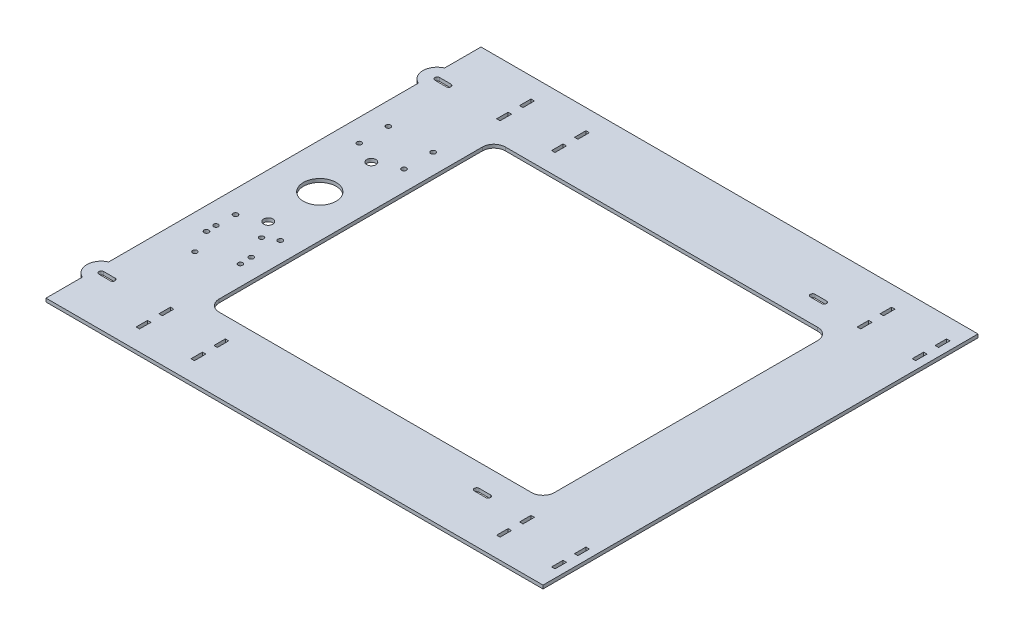
from build123d import *

# Parameters (mm, degrees)
SKETCH1_W           = 434.18
SKETCH1_H           = 380
BOSS_EXTRUDE1_DEPTH = 3
SKETCH2_W           = 250
SKETCH2_H           = 250
CUT_EXTRUDE1_DEPTH  = 4
SKETCH3_W           = 3
SKETCH3_H           = 10
CUT_EXTRUDE2_DEPTH  = 4
SKETCH6_R           = 14.2875
SKETCH6_R_2         = 2
SKETCH6_R_3         = 2.083333333
SKETCH6_R_4         = 4
CUT_EXTRUDE3_DEPTH  = 4
SKETCH7_W           = 83.283399819
SKETCH7_H           = 250
CUT_EXTRUDE4_DEPTH  = 4
FILLET1_R           = 10
CUT_EXTRUDE5_DEPTH  = 4
SKETCH9_R           = 12.5
BOSS_EXTRUDE2_DEPTH = 3


with BuildPart() as part:
    # Sketch1 → Boss-Extrude1 (new body)
    with BuildSketch(Plane(origin=(0, 0, 0), x_dir=(1, 0, 0), z_dir=(0, 1, 0))):
        Rectangle(SKETCH1_W, SKETCH1_H)
    extrude(amount=BOSS_EXTRUDE1_DEPTH)

    # Sketch2 → Cut-Extrude1 (cut, through all)
    with BuildSketch(Plane(origin=(0, 3, 0), x_dir=(1, 0, 0), z_dir=(0, 1, 0))):
        with Locations((27.09, 0)):
            Rectangle(SKETCH2_W, SKETCH2_H)
    extrude(amount=-CUT_EXTRUDE1_DEPTH, mode=Mode.SUBTRACT)

    # Sketch3 → Cut-Extrude2 (cut, through all)
    with BuildSketch(Plane(origin=(0, 3, 0), x_dir=(1, 0, 0), z_dir=(0, 1, 0))):
        with Locations((160.59, -147.5)):
            Rectangle(SKETCH3_W, SKETCH3_H)
        with Locations((160.59, -167.5)):
            Rectangle(SKETCH3_W, SKETCH3_H)
        with Locations((208.59, -147.5)):
            Rectangle(SKETCH3_W, SKETCH3_H)
        with Locations((208.59, -167.5)):
            Rectangle(SKETCH3_W, SKETCH3_H)
        with Locations((-154.41, -147.5)):
            Rectangle(SKETCH3_W, SKETCH3_H)
        with Locations((-154.41, -167.5)):
            Rectangle(SKETCH3_W, SKETCH3_H)
        with Locations((-106.41, -167.5)):
            Rectangle(SKETCH3_W, SKETCH3_H)
        with Locations((-106.41, -147.5)):
            Rectangle(SKETCH3_W, SKETCH3_H)
        with Locations((208.59, 147.5)):
            Rectangle(SKETCH3_W, SKETCH3_H)
        with Locations((208.59, 167.5)):
            Rectangle(SKETCH3_W, SKETCH3_H)
        with Locations((160.59, 167.5)):
            Rectangle(SKETCH3_W, SKETCH3_H)
        with Locations((160.59, 147.5)):
            Rectangle(SKETCH3_W, SKETCH3_H)
        with Locations((-106.41, 147.5)):
            Rectangle(SKETCH3_W, SKETCH3_H)
        with Locations((-106.41, 167.5)):
            Rectangle(SKETCH3_W, SKETCH3_H)
        with Locations((-154.41, 167.5)):
            Rectangle(SKETCH3_W, SKETCH3_H)
        with Locations((-154.41, 147.5)):
            Rectangle(SKETCH3_W, SKETCH3_H)
    extrude(amount=-CUT_EXTRUDE2_DEPTH, mode=Mode.SUBTRACT)

    # Sketch6 → Cut-Extrude3 (cut, through all)
    with BuildSketch(Plane(origin=(0, 3, 0), x_dir=(1, 0, 0), z_dir=(0, 1, 0))):
        with Locations((-177.91, 10)):
            Circle(SKETCH6_R)
        with Locations((-197.793356941, -60.788209542)):
            Circle(SKETCH6_R_2)
        with Locations((-187.137790458, -89.899356941)):
            Circle(SKETCH6_R_2)
        with Locations((-158.026643059, -79.243790458)):
            Circle(SKETCH6_R_2)
        with Locations((-168.682209542, -50.132643059)):
            Circle(SKETCH6_R_2)
        with Locations((-158.345, 64.0505)):
            Circle(SKETCH6_R_3)
        with Locations((-197.475, 64.0505)):
            Circle(SKETCH6_R_3)
        with Locations((-197.475, -44.0505)):
            Circle(SKETCH6_R_3)
        with Locations((-158.345, -44.0505)):
            Circle(SKETCH6_R_3)
        with Locations((-197.475, 89.4505)):
            Circle(SKETCH6_R_3)
        with Locations((-158.345, 89.4505)):
            Circle(SKETCH6_R_3)
        with Locations((-158.345, -69.4505)):
            Circle(SKETCH6_R_3)
        with Locations((-197.475, -69.4505)):
            Circle(SKETCH6_R_3)
        with Locations((-177.91, -35)):
            Circle(SKETCH6_R_4)
        with Locations((-177.91, 55)):
            Circle(SKETCH6_R_4)
    extrude(amount=-CUT_EXTRUDE3_DEPTH, mode=Mode.SUBTRACT)

    # Sketch7 → Cut-Extrude4 (cut, through all)
    with BuildSketch(Plane(origin=(0, 3, 0), x_dir=(1, 0, 0), z_dir=(0, 1, 0))):
        with Locations((-99.169040346, 0)):
            Rectangle(SKETCH7_W, SKETCH7_H)
    extrude(amount=-CUT_EXTRUDE4_DEPTH, mode=Mode.SUBTRACT)

    # Fillet1
    fillet1_edges = [part.edges().sort_by_distance(p)[0] for p in [
        (152.09, 1.5, -125),
        (152.09, 1.5, 125),
        (-140.810740255, 1.5, -125),
        (-140.810740255, 1.5, 125),
    ]]
    fillet(fillet1_edges, radius=FILLET1_R)

    # Sketch8 → Cut-Extrude5 (cut, through all)
    with BuildSketch(Plane(origin=(0, 3, 0), x_dir=(1, 0, 0), z_dir=(0, 1, 0))):
        with BuildLine():
            Line((-212.09, 148.805), (-202.09, 148.805))
            ThreePointArc((-202.09, 148.805), (-200.035, 146.75), (-202.09, 144.695))
            Line((-202.09, 144.695), (-212.09, 144.695))
            ThreePointArc((-212.09, 144.695), (-214.145, 146.75), (-212.09, 148.805))
        make_face()
        with BuildLine():
            Line((-212.09, -144.695), (-202.09, -144.695))
            ThreePointArc((-202.09, -144.695), (-200.035, -146.75), (-202.09, -148.805))
            Line((-202.09, -148.805), (-212.09, -148.805))
            ThreePointArc((-212.09, -148.805), (-214.145, -146.75), (-212.09, -144.695))
        make_face()
        with BuildLine():
            Line((115.91, -144.695), (125.91, -144.695))
            ThreePointArc((125.91, -144.695), (127.965, -146.75), (125.91, -148.805))
            Line((125.91, -148.805), (115.91, -148.805))
            ThreePointArc((115.91, -148.805), (113.855, -146.75), (115.91, -144.695))
        make_face()
        with BuildLine():
            Line((115.91, 148.805), (125.91, 148.805))
            ThreePointArc((125.91, 148.805), (127.965, 146.75), (125.91, 144.695))
            Line((125.91, 144.695), (115.91, 144.695))
            ThreePointArc((115.91, 144.695), (113.855, 146.75), (115.91, 148.805))
        make_face()
    extrude(amount=-CUT_EXTRUDE5_DEPTH, mode=Mode.SUBTRACT)

    # Sketch9 → Boss-Extrude2 (add)
    with BuildSketch(Plane(origin=(0, 3, 0), x_dir=(1, 0, 0), z_dir=(0, 1, 0))):
        with Locations((-212.09, 146.75)):
            Circle(SKETCH9_R)
        with BuildLine():
            ThreePointArc((-212.09, 148.805), (-214.145, 146.75), (-212.09, 144.695))
            Line((-212.09, 144.695), (-202.09, 144.695))
            ThreePointArc((-202.09, 144.695), (-200.035, 146.75), (-202.09, 148.805))
            Line((-202.09, 148.805), (-212.09, 148.805))
        make_face(mode=Mode.SUBTRACT)
        with Locations((-212.09, -146.75)):
            Circle(SKETCH9_R)
        with BuildLine():
            ThreePointArc((-212.09, -144.695), (-214.145, -146.75), (-212.09, -148.805))
            Line((-212.09, -148.805), (-202.09, -148.805))
            ThreePointArc((-202.09, -148.805), (-200.035, -146.75), (-202.09, -144.695))
            Line((-202.09, -144.695), (-212.09, -144.695))
        make_face(mode=Mode.SUBTRACT)
    extrude(amount=-BOSS_EXTRUDE2_DEPTH)


solid = part.part
